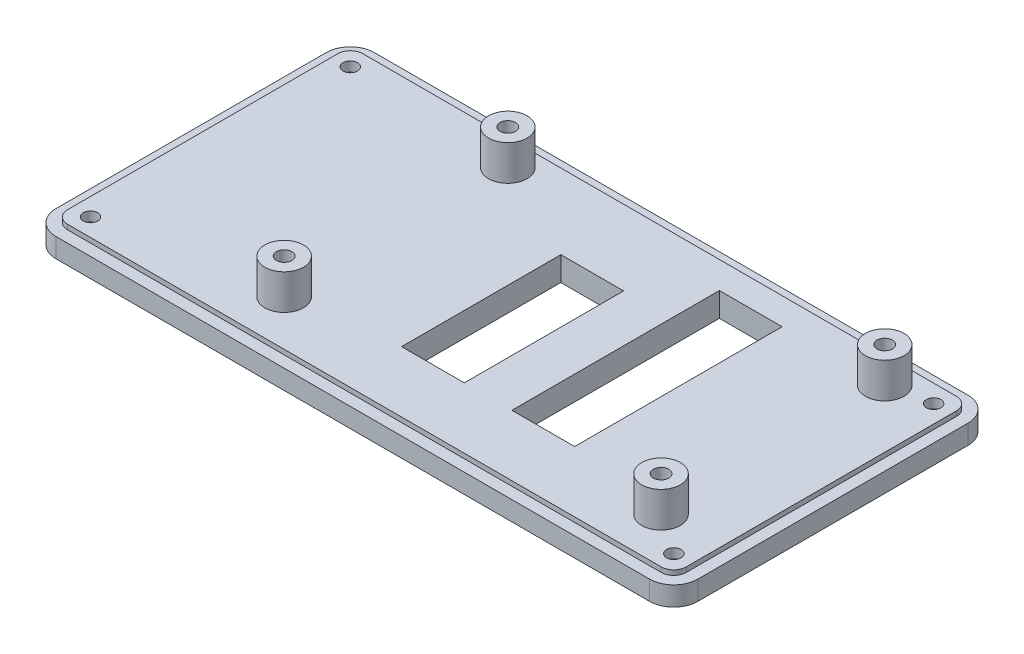
from build123d import *

# Parameters (mm, degrees)
EXTRUDE_1_DEPTH     = 4
EXTRUDE_2_DEPTH     = 1
SKETCH_3_W          = 13
SKETCH_3_H          = 43
SKETCH_3_H_2        = 33
CUT_EXTRUDE_1_DEPTH = 6
SKETCH_4_R          = 4
SKETCH_4_R_2        = 1.6
EXTRUDE_4_DEPTH     = 7.3
SKETCH_5_R          = 1.5
CUT_EXTRUDE_2_DEPTH = 7.3
SKETCH_6_R          = 3.5
CUT_EXTRUDE_3_DEPTH = 3


with BuildPart() as part:
    # 스케치1 → 보스-돌출1 (new body)
    with BuildSketch(Plane(origin=(0, 0, 0), x_dir=(1, 0, 0), z_dir=(0, 1, 0))):
        with BuildLine():
            Line((61.498388188, 66.010476517), (-61.501611812, 65.989522963))
            ThreePointArc((-61.501611812, 65.989522963), (-65.036624731, 64.524771992), (-66.500805906, 60.989523028))
            Line((-66.500805906, 60.989523028), (-66.500805906, 4.989523158))
            ThreePointArc((-66.500805906, 4.989523158), (-65.03605487, 1.453704333), (-61.5, -0.010476777))
            Line((-61.5, -0.010476777), (61.5, 0.010476777))
            ThreePointArc((61.5, 0.010476777), (65.035012919, 1.475227749), (66.499194094, 5.010476712))
            Line((66.499194094, 5.010476712), (66.499194094, 61.010476582))
            ThreePointArc((66.499194094, 61.010476582), (65.034443058, 64.546295408), (61.498388188, 66.010476517))
        make_face()
    extrude(amount=EXTRUDE_1_DEPTH)

    # 스케치2 → 보스-돌출2 (add)
    with BuildSketch(Plane(origin=(0, 4, 0), x_dir=(1, 0, 0), z_dir=(0, 1, 0))):
        with BuildLine():
            Line((61.498751287, 63.610473876), (-61.501248713, 63.589525677))
            ThreePointArc((-61.501248713, 63.589525677), (-63.339440086, 62.827846783), (-64.100805906, 60.989525714))
            Line((-64.100805906, 60.989525714), (-64.100805906, 4.989525834))
            ThreePointArc((-64.100805906, 4.989525834), (-63.339126974, 3.150891653), (-61.500363098, 2.389525871))
            Line((-61.500363098, 2.389525871), (61.499636902, 2.410474071))
            ThreePointArc((61.499636902, 2.410474071), (63.337828275, 3.172152965), (64.099194094, 5.010474033))
            Line((64.099194094, 5.010474033), (64.099194094, 61.010473914))
            ThreePointArc((64.099194094, 61.010473914), (63.337515162, 62.849108095), (61.498751287, 63.610473876))
        make_face()
    extrude(amount=EXTRUDE_2_DEPTH)

    # 스케치3 → 컷-돌출1 (cut, through all)
    with BuildSketch(Plane(origin=(0, 5, 0), x_dir=(1, 0, 0), z_dir=(0, 1, 0))):
        with Locations((24.440725111, 36.53850122)):
            Rectangle(SKETCH_3_W, SKETCH_3_H)
        with Locations((1.580725111, 31.53850122)):
            Rectangle(SKETCH_3_W, SKETCH_3_H_2)
    extrude(amount=-CUT_EXTRUDE_1_DEPTH, mode=Mode.SUBTRACT)

    # 스케치4 → 보스-돌출4 (add)
    with BuildSketch(Plane(origin=(0, 5, 0), x_dir=(1, 0, 0), z_dir=(0, 1, 0))):
        with Locations((-26.042417718, 58.176282553)):
            Circle(SKETCH_4_R)
        with Locations((-26.042417718, 58.176282553)):
            Circle(SKETCH_4_R_2, mode=Mode.SUBTRACT)
        with Locations((52.062582282, 58.176282553)):
            Circle(SKETCH_4_R)
        with Locations((52.062582282, 58.176282553)):
            Circle(SKETCH_4_R_2, mode=Mode.SUBTRACT)
        with Locations((-26.042417718, 11.821282553)):
            Circle(SKETCH_4_R)
        with Locations((-26.042417718, 11.821282553)):
            Circle(SKETCH_4_R_2, mode=Mode.SUBTRACT)
        with Locations((52.062582282, 11.821282553)):
            Circle(SKETCH_4_R)
        with Locations((52.062582282, 11.821282553)):
            Circle(SKETCH_4_R_2, mode=Mode.SUBTRACT)
    extrude(amount=EXTRUDE_4_DEPTH)

    # 스케치5 → 컷-돌출2 (cut)
    with BuildSketch(Plane(origin=(0, 5, 0), x_dir=(1, 0, 0), z_dir=(0, 1, 0))):
        with Locations((60.440145734, 59.928842317)):
            Circle(SKETCH_5_R)
        with Locations((60.440145734, 6.092110978)):
            Circle(SKETCH_5_R)
        with Locations((-60.442726529, 59.928842317)):
            Circle(SKETCH_5_R)
        with Locations((-60.442726529, 6.092110978)):
            Circle(SKETCH_5_R)
    extrude(amount=-CUT_EXTRUDE_2_DEPTH, mode=Mode.SUBTRACT)

    # 스케치6 → 컷-돌출3 (cut)
    with BuildSketch(Plane.XZ):
        with Locations((60.450353981, -59.918545221)):
            Circle(SKETCH_6_R)
        with Locations((60.441182673, -6.081814663)):
            Circle(SKETCH_6_R)
        with Locations((-60.432516528, -59.939138113)):
            Circle(SKETCH_6_R)
        with Locations((-60.441687836, -6.102407556)):
            Circle(SKETCH_6_R)
    extrude(amount=-CUT_EXTRUDE_3_DEPTH, mode=Mode.SUBTRACT)


solid = part.part
